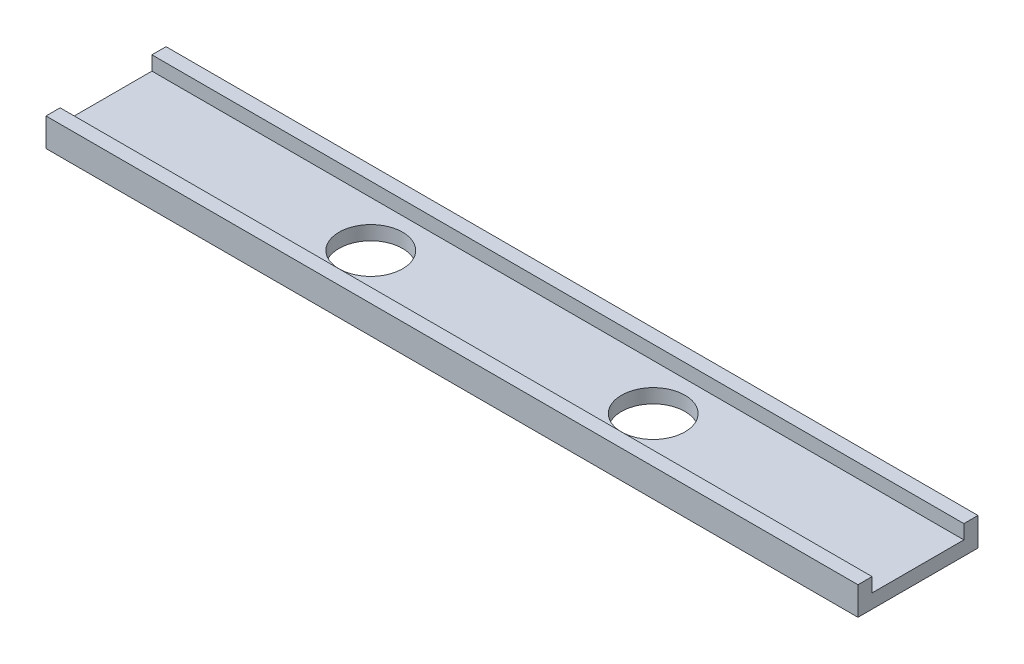
from build123d import *

# Parameters (mm, degrees)
SKETCH5_R               = 9
F_2_STK_18_HULLER_DEPTH = 13.167105011
SKETCH3_W               = 62.936012514
SKETCH3_H               = 32.167105011
DUMMY_CUT_AWAY1_DEPTH   = 35
SKETCH6_W               = 62.936012514
SKETCH6_H               = 32.167105011
DUMMY_CUT_AWAY2_DEPTH   = 35
DUMMY_RET1_DEPTH        = 65


with BuildPart() as part:
    # Sweep1: sweep along a path in Sketch1
    with BuildLine(Plane.XY) as sweep1_path:
        Line((-225.364862075, -4.470649394), (-218.416595736, 1.359638329))
        ThreePointArc((-218.416595736, 1.359638329), (-214.807386139, 3.443416461), (-210.703144419, 4.167105011))
        Line((-210.703144419, 4.167105011), (-188.097668128, 4.167105011))
        ThreePointArc((-188.097668128, 4.167105011), (-186.013889996, 3.984798048), (-183.993426408, 3.443416461))
        Line((-183.993426408, 3.443416461), (-177.3495012, 1.025225447))
        ThreePointArc((-177.3495012, 1.025225447), (-174.487177784, 0.258268199), (-171.535158764, 0))
        Line((-171.535158764, 0), (-58.464841236, 0))
        ThreePointArc((-58.464841236, 0), (-55.512822216, 0.258268199), (-52.6504988, 1.025225447))
        Line((-52.6504988, 1.025225447), (-46.006573592, 3.443416461))
        ThreePointArc((-46.006573592, 3.443416461), (-43.986110004, 3.984798048), (-41.902331872, 4.167105011))
        Line((-41.902331872, 4.167105011), (-19.296855581, 4.167105011))
        ThreePointArc((-19.296855581, 4.167105011), (-15.192613861, 3.443416461), (-11.583404264, 1.359638329))
        Line((-11.583404264, 1.359638329), (-4.635137925, -4.470649394))
    # Sketch2 → Sweep1 (sweep)
    with BuildSketch(Plane(origin=(-4.635137925, -4.470649394, 0), x_dir=(0, 0, -1), z_dir=(0.766044443, -0.64278761, 0))):
        Polygon((0, 0), (0.5, 0), (0.5, 4), (4.5, 4), (4.5, -4), (-29.5, -4), (-29.5, 4), (-25.5, 4), (-25.5, 0), align=None)
    sweep(path=sweep1_path.line)

    # Sketch5 → 2 stk ø18 huller (cut, through all)
    with BuildSketch(Plane.XZ.offset(4)):
        with Locations((-75, 12.5)):
            Circle(SKETCH5_R)
        with Locations((-155, 12.5)):
            Circle(SKETCH5_R)
    extrude(amount=-F_2_STK_18_HULLER_DEPTH, mode=Mode.SUBTRACT)

    # Sketch3 → Dummy cut away1 (cut, through all)
    with BuildSketch(Plane.XY.offset(29.5)):
        with Locations((-33.531993743, 2.083552506)):
            Rectangle(SKETCH3_W, SKETCH3_H)
    extrude(amount=-DUMMY_CUT_AWAY1_DEPTH, mode=Mode.SUBTRACT)

    # Sketch6 → Dummy cut away2 (cut, through all)
    with BuildSketch(Plane.XY.offset(29.5)):
        with Locations((-196.468006257, 2.083552506)):
            Rectangle(SKETCH6_W, SKETCH6_H)
    extrude(amount=-DUMMY_CUT_AWAY2_DEPTH, mode=Mode.SUBTRACT)

    # Sketch4 → Dummy ret1 (add)
    with BuildSketch(Plane.ZY.offset(165)):
        Polygon((29.5, -4), (29.5, 4), (25.5, 4), (25.5, 0), (-0.5, 0), (-0.5, 4), (-4.5, 4), (-4.5, -4), align=None)
    dummy_ret1 = extrude(amount=DUMMY_RET1_DEPTH)

    # Mirror1: Dummy ret1 across plane
    add(dummy_ret1.mirror(Plane(origin=(-115, 4, 29.5), x_dir=(0, 0, 1), z_dir=(-1, 0, 0))))


solid = part.part
